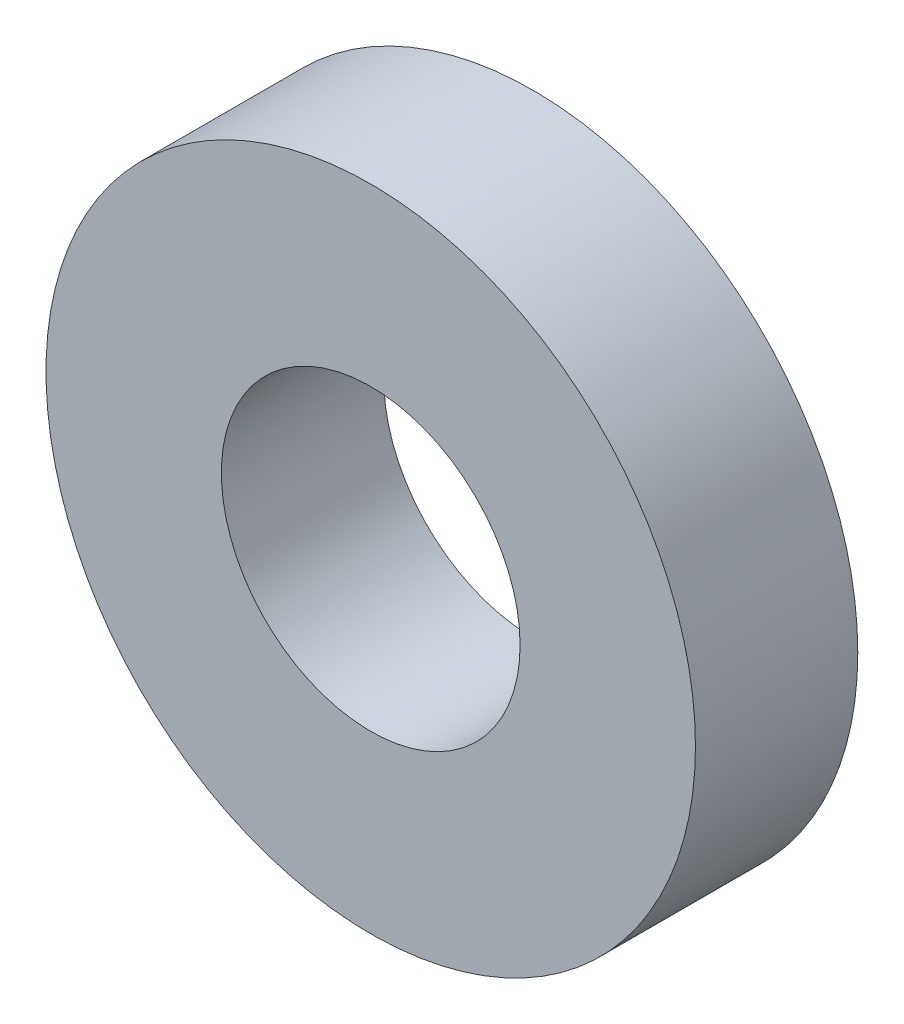
from build123d import *

# Parameters (mm, degrees)
SKETCH1_R      = 3.175
SKETCH1_R_2    = 1.4605
EXTRUDE1_DEPTH = 0.79375


with BuildPart() as part:
    # Sketch1 → Extrude1 (new body, symmetric)
    with BuildSketch(Plane.XY):
        Circle(SKETCH1_R)
        Circle(SKETCH1_R_2, mode=Mode.SUBTRACT)
    extrude(amount=EXTRUDE1_DEPTH, both=True)


solid = part.part
